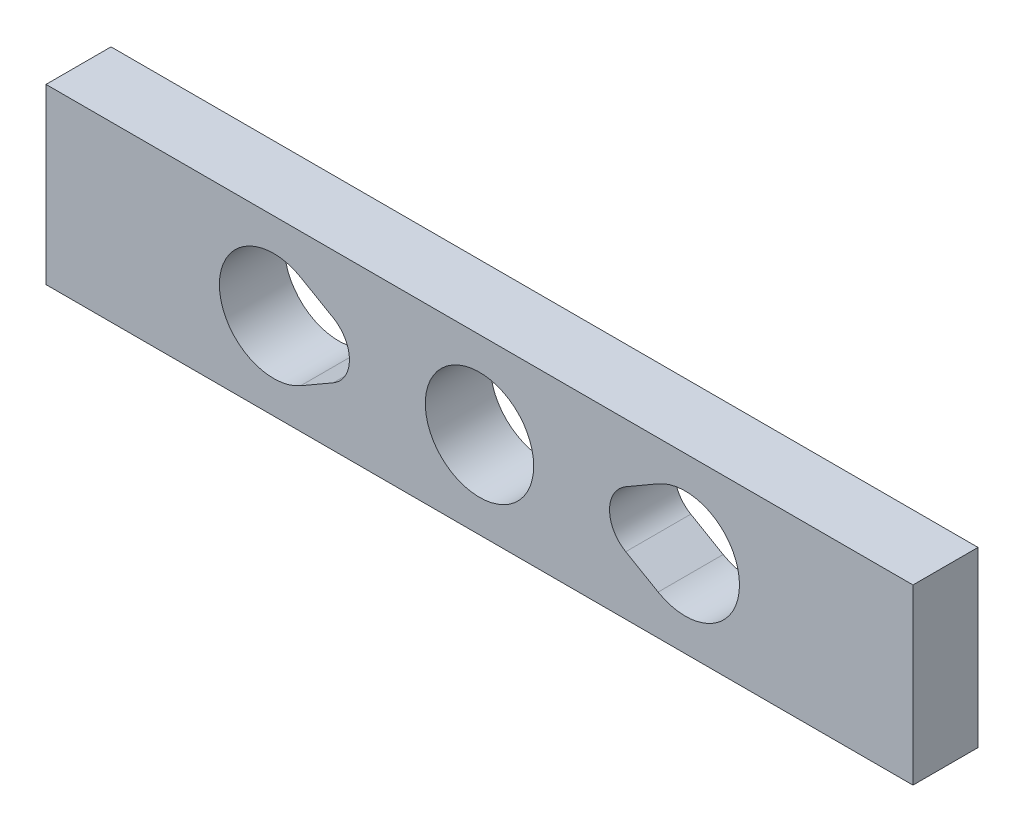
from build123d import *

# Parameters (mm, degrees)
SKETCH1_W           = 40
SKETCH1_H           = 8
SKETCH1_R           = 2.5
BOSS_EXTRUDE1_DEPTH = 3


with BuildPart() as part:
    # Sketch1 → Boss-Extrude1 (new body)
    with BuildSketch(Plane.XY):
        with Locations((0.003679189, 1.000819415)):
            Rectangle(SKETCH1_W, SKETCH1_H)
        with BuildLine():
            Line((-8.246320143, 3.165882539), (-6.746321478, 2.29985729))
            ThreePointArc((-6.746321478, 2.29985729), (-5.996321879, 1.000819415), (-6.746321478, -0.298218459))
            Line((-6.746321478, -0.298218459), (-8.246320143, -1.164243709))
            ThreePointArc((-8.246320143, -1.164243709), (-10.636363972, -1.224107908), (-11.983789404, 0.750819415))
            ThreePointArc((-11.983789404, 0.750819415), (-11.996320811, 1.000819415), (-11.983789404, 1.250819415))
            ThreePointArc((-11.983789404, 1.250819415), (-10.636363972, 3.225746738), (-8.246320143, 3.165882539))
        make_face(mode=Mode.SUBTRACT)
        with Locations((0.003679189, 1.000819415)):
            Circle(SKETCH1_R, mode=Mode.SUBTRACT)
        with BuildLine():
            Line((8.244905291, 3.163423753), (8.247736867, 3.165063509))
            ThreePointArc((8.247736867, 3.165063509), (10.638467861, 3.226118523), (11.986620451, 1.250819308))
            ThreePointArc((11.986620451, 1.250819308), (11.999151848, 1.000819415), (11.986620451, 0.750819522))
            ThreePointArc((11.986620451, 0.750819522), (10.637740693, -1.224851841), (8.246322819, -1.162606427))
            Line((8.246322819, -1.162606427), (6.751978531, -0.297235948))
            ThreePointArc((6.751978531, -0.297235948), (6.003678121, 1.000819415), (6.751978531, 2.298874779))
            Line((6.751978531, 2.298874779), (8.244905291, 3.163423753))
        make_face(mode=Mode.SUBTRACT)
    extrude(amount=BOSS_EXTRUDE1_DEPTH)


solid = part.part
